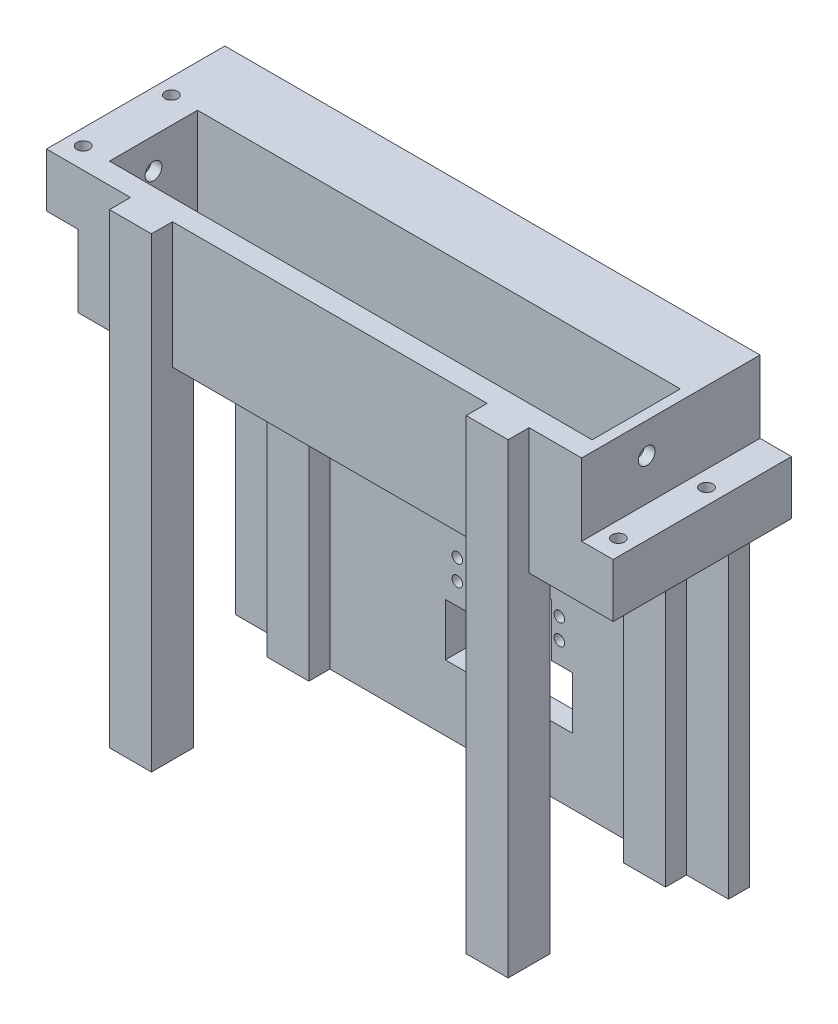
from build123d import *

# Parameters (mm, degrees)
SKETCH2_W            = 230
SKETCH2_H            = 42
BOSS_EXTRUDE1_DEPTH  = 60
BOSS_EXTRUDE2_DEPTH  = 150
SKETCH5_R            = 4
CUT_EXTRUDE1_DEPTH   = 277
SKETCH7_R            = 4
BOSS_EXTRUDE3_DEPTH  = 20
SKETCH7_2_R          = 4
CUT_EXTRUDE2_DEPTH   = 10
SKETCH8_W            = 62
SKETCH8_H            = 24.6
BOSS_EXTRUDE4_DEPTH  = 14
SKETCH9_W            = 62
SKETCH9_H            = 24.6
BOSS_EXTRUDE5_DEPTH  = 14
SKETCH15_W           = 42
SKETCH15_H           = 60
SKETCH15_R           = 4
CUT_EXTRUDE3_DEPTH   = 5
SKETCH17_W           = 42
SKETCH17_H           = 60
SKETCH17_R           = 4
CUT_EXTRUDE4_DEPTH   = 5
SKETCH18_W           = 1
SKETCH18_H           = 62
BOSS_EXTRUDE9_DEPTH  = 24.6
SKETCH18_3_R         = 3
CUT_EXTRUDE5_DEPTH   = 35
SKETCH19_W           = 1
SKETCH19_H           = 62
BOSS_EXTRUDE10_DEPTH = 24.6
SKETCH19_3_R         = 3
CUT_EXTRUDE6_DEPTH   = 27
SKETCH20_W           = 15
SKETCH20_H           = 62
SKETCH20_R           = 3
BOSS_EXTRUDE11_DEPTH = 1
SKETCH21_W           = 15
SKETCH21_H           = 62
SKETCH21_R           = 3
BOSS_EXTRUDE12_DEPTH = 1
SKETCH23_W           = 255
SKETCH23_H           = 10
BOSS_EXTRUDE13_DEPTH = 150
SKETCH25_W           = 251.390716306
SKETCH25_H           = 22.262694164
CUT_EXTRUDE7_DEPTH   = 150
BOSS_EXTRUDE16_DEPTH = 17
CUT_EXTRUDE8_DEPTH   = 150
SKETCH28_W           = 255
SKETCH28_H           = 13
CUT_EXTRUDE9_DEPTH   = 167
BOSS_EXTRUDE18_DEPTH = 6
CUT_EXTRUDE10_DEPTH  = 43
SKETCH32_W           = 10
SKETCH32_H           = 20
BOSS_EXTRUDE19_DEPTH = 7.5
SKETCH33_W           = 10
SKETCH33_H           = 20
BOSS_EXTRUDE20_DEPTH = 8
SKETCH38_R           = 2.5
CUT_EXTRUDE12_DEPTH  = 16
SKETCH40_W           = 20.026518065
SKETCH40_H           = 12.666252083
CUT_EXTRUDE13_DEPTH  = 116
SKETCH41_W           = 84.423481935
SKETCH41_H           = 10
SKETCH41_W_2         = 110.05
BOSS_EXTRUDE21_DEPTH = 61.47
SKETCH42_W           = 10
SKETCH42_H           = 25
CUT_EXTRUDE14_DEPTH  = 10
SKETCH40_3_W         = 20
SKETCH40_3_H         = 10
BOSS_EXTRUDE22_DEPTH = 162.1
SKETCH43_W           = 10
SKETCH43_H           = 31.300449652
BOSS_EXTRUDE23_DEPTH = 40.5
BOSS_EXTRUDE24_START = -60
SKETCH46_W           = 20
SKETCH46_H           = 20
BOSS_EXTRUDE24_DEPTH = 222.1
SKETCH48_R           = 2
CUT_EXTRUDE15_DEPTH  = 30


with BuildPart() as part:
    # Sketch2 → Boss-Extrude1 (new body)
    with BuildSketch(Plane(origin=(0, 0, 0), x_dir=(1, 0, 0), z_dir=(0, 1, 0))):
        Polygon((-125, -31), (125, -31), (125, -21), (125, 0), (125, 21), (125, 31), (-125, 31), (-125, 21), (-125, 0), (-125, -21), align=None)
        Rectangle(SKETCH2_W, SKETCH2_H, mode=Mode.SUBTRACT)
    extrude(amount=BOSS_EXTRUDE1_DEPTH)

    # Sketch4 → Boss-Extrude2 (add)
    with BuildSketch(Plane.XZ):
        Polygon((125, 31), (-125, 31), (-125, 21), (-115, 21), (125, 21), align=None)
    extrude(amount=BOSS_EXTRUDE2_DEPTH)

    # Sketch5 → Cut-Extrude1 (cut)
    with BuildSketch(Plane.ZY.offset(125)):
        with Locations((0, 15.395589143)):
            Circle(SKETCH5_R)
        with Locations((0, 45.395589143)):
            Circle(SKETCH5_R)
    extrude(amount=-CUT_EXTRUDE1_DEPTH, mode=Mode.SUBTRACT)

    # Sketch7 → Boss-Extrude3 (add)
    with BuildSketch(Plane(origin=(125, 0, 0), x_dir=(0, 0, -1), z_dir=(1, 0, 0))):
        Polygon((-21, -150), (-31, -150), (-31, 60), (31, 60), (31, 0), (-21, 0), align=None)
        with Locations((0, 15.395589143)):
            Circle(SKETCH7_R, mode=Mode.SUBTRACT)
        with Locations((0, 45.395589143)):
            Circle(SKETCH7_R, mode=Mode.SUBTRACT)
    extrude(amount=-BOSS_EXTRUDE3_DEPTH)

    # Sketch7_2 → Cut-Extrude2 (cut)
    with BuildSketch(Plane(origin=(125, 0, 0), x_dir=(0, 0, -1), z_dir=(1, 0, 0))):
        Polygon((-21, -150), (-31, -150), (-31, 60), (31, 60), (31, 0), (-21, 0), align=None)
        with Locations((0, 15.395589143)):
            Circle(SKETCH7_2_R, mode=Mode.SUBTRACT)
        with Locations((0, 45.395589143)):
            Circle(SKETCH7_2_R, mode=Mode.SUBTRACT)
    extrude(amount=-CUT_EXTRUDE2_DEPTH, mode=Mode.SUBTRACT)

    # Sketch8 → Boss-Extrude4 (add)
    with BuildSketch(Plane(origin=(115, 0, 0), x_dir=(0, 0, -1), z_dir=(1, 0, 0))):
        with Locations((0, 12.3)):
            Rectangle(SKETCH8_W, SKETCH8_H)
    extrude(amount=BOSS_EXTRUDE4_DEPTH)

    # Sketch9 → Boss-Extrude5 (add)
    with BuildSketch(Plane.ZY.offset(125)):
        with Locations((0, 47.7)):
            Rectangle(SKETCH9_W, SKETCH9_H)
    extrude(amount=BOSS_EXTRUDE5_DEPTH)

    # Sketch15 → Cut-Extrude3 (cut)
    with BuildSketch(Plane.ZY.offset(-105)):
        with Locations((0, 30)):
            Rectangle(SKETCH15_W, SKETCH15_H)
        with Locations((0, 15.395589143)):
            Circle(SKETCH15_R, mode=Mode.SUBTRACT)
        with Locations((0, 45.395589143)):
            Circle(SKETCH15_R, mode=Mode.SUBTRACT)
    extrude(amount=-CUT_EXTRUDE3_DEPTH, mode=Mode.SUBTRACT)

    # Sketch17 → Cut-Extrude4 (cut)
    with BuildSketch(Plane(origin=(-115, 0, 0), x_dir=(0, 0, -1), z_dir=(1, 0, 0))):
        with Locations((0, 30)):
            Rectangle(SKETCH17_W, SKETCH17_H)
        with Locations((0, 45.395589143)):
            Circle(SKETCH17_R, mode=Mode.SUBTRACT)
        with Locations((0, 15.395589143)):
            Circle(SKETCH17_R, mode=Mode.SUBTRACT)
    extrude(amount=-CUT_EXTRUDE4_DEPTH, mode=Mode.SUBTRACT)

    # Sketch18 → Boss-Extrude9 (add)
    with BuildSketch(Plane.XZ.offset(-35.4)):
        with Locations((-139.5, 0)):
            Rectangle(SKETCH18_W, SKETCH18_H)
    extrude(amount=-BOSS_EXTRUDE9_DEPTH)

    # Sketch18_3 → Cut-Extrude5 (cut)
    with BuildSketch(Plane.XZ.offset(-35.4)):
        with Locations((-132.5, 21)):
            Circle(SKETCH18_3_R)
        with Locations((-132.5, -21)):
            Circle(SKETCH18_3_R)
    extrude(amount=-CUT_EXTRUDE5_DEPTH, mode=Mode.SUBTRACT)

    # Sketch19 → Boss-Extrude10 (add)
    with BuildSketch(Plane(origin=(0, 24.6, 0), x_dir=(1, 0, 0), z_dir=(0, 1, 0))):
        with Locations((129.5, 0)):
            Rectangle(SKETCH19_W, SKETCH19_H)
    extrude(amount=-BOSS_EXTRUDE10_DEPTH)

    # Sketch19_3 → Cut-Extrude6 (cut)
    with BuildSketch(Plane(origin=(0, 24.6, 0), x_dir=(1, 0, 0), z_dir=(0, 1, 0))):
        with Locations((122.5, 21)):
            Circle(SKETCH19_3_R)
        with Locations((122.5, -21)):
            Circle(SKETCH19_3_R)
    extrude(amount=-CUT_EXTRUDE6_DEPTH, mode=Mode.SUBTRACT)

    # Sketch20 → Boss-Extrude11 (add)
    with BuildSketch(Plane(origin=(0, 24.6, 0), x_dir=(1, 0, 0), z_dir=(0, 1, 0))):
        with Locations((122.5, 0)):
            Rectangle(SKETCH20_W, SKETCH20_H)
        with Locations((122.5, -21)):
            Circle(SKETCH20_R, mode=Mode.SUBTRACT)
        with Locations((122.5, 21)):
            Circle(SKETCH20_R, mode=Mode.SUBTRACT)
    extrude(amount=BOSS_EXTRUDE11_DEPTH)

    # Sketch21 → Boss-Extrude12 (add)
    with BuildSketch(Plane.XZ.offset(-35.4)):
        with Locations((-132.5, 0)):
            Rectangle(SKETCH21_W, SKETCH21_H)
        with Locations((-132.5, 21)):
            Circle(SKETCH21_R, mode=Mode.SUBTRACT)
        with Locations((-132.5, -21)):
            Circle(SKETCH21_R, mode=Mode.SUBTRACT)
    extrude(amount=BOSS_EXTRUDE12_DEPTH)

    # Sketch23 → Boss-Extrude13 (add)
    with BuildSketch(Plane.XZ):
        with Locations((2.5, -26)):
            Rectangle(SKETCH23_W, SKETCH23_H)
    extrude(amount=BOSS_EXTRUDE13_DEPTH)

    # Sketch25 → Cut-Extrude7 (cut)
    with BuildSketch(Plane.XZ):
        with Locations((-4.583562675, 27.327499947)):
            Rectangle(SKETCH25_W, SKETCH25_H)
    extrude(amount=CUT_EXTRUDE7_DEPTH, mode=Mode.SUBTRACT)

    # Sketch26 → Boss-Extrude16 (add)
    with BuildSketch(Plane(origin=(0, 0, -31), x_dir=(-1, 0, 0), z_dir=(0, 0, -1))):
        Polygon((125, -150), (-130, -150), (-130, 25.6), (-115, 25.6), (-115, 60), (125, 60), (140, 60), (140, 34.4), (125, 34.4), (125, 25.6), align=None)
    extrude(amount=BOSS_EXTRUDE16_DEPTH)

    # Sketch27 → Cut-Extrude8 (cut)
    with BuildSketch(Plane.XZ):
        Polygon((110, -31), (132.347433228, -31), (132.347433228, -21), (110, -21), (-153.412168614, -21), (-153.412168614, -31), align=None)
    extrude(amount=CUT_EXTRUDE8_DEPTH, mode=Mode.SUBTRACT)

    # Sketch28 → Cut-Extrude9 (cut)
    with BuildSketch(Plane.XZ):
        with Locations((2.5, -37.5)):
            Rectangle(SKETCH28_W, SKETCH28_H)
    extrude(amount=CUT_EXTRUDE9_DEPTH, mode=Mode.SUBTRACT)

    # Sketch29 → Boss-Extrude18 (add)
    with BuildSketch(Plane(origin=(0, 0, -48), x_dir=(-1, 0, 0), z_dir=(0, 0, -1))):
        Polygon((125, -150), (-130, -150), (-130, 25.6), (-115, 25.6), (-115, 60), (125, 60), (140, 60), (140, 34.4), (125, 34.4), (125, 25.6), align=None)
    extrude(amount=BOSS_EXTRUDE18_DEPTH)

    # Sketch31 → Cut-Extrude10 (cut)
    with BuildSketch(Plane.XY.offset(-44)):
        Polygon((33.05, -150), (130, -150), (130, -100.63), (33.05, -100.63), (33.05, -80.63), (-22.95, -80.63), (-22.95, -100.63), (-125, -100.63), (-125, -150), align=None)
    extrude(amount=-CUT_EXTRUDE10_DEPTH, mode=Mode.SUBTRACT)

    # Sketch32 → Boss-Extrude19 (add)
    with BuildSketch(Plane.ZY.offset(-33.05)):
        with Locations((-49, -90.63)):
            Rectangle(SKETCH32_W, SKETCH32_H)
    extrude(amount=BOSS_EXTRUDE19_DEPTH)

    # Sketch33 → Boss-Extrude20 (add)
    with BuildSketch(Plane(origin=(-22.95, 0, 0), x_dir=(0, 0, -1), z_dir=(1, 0, 0))):
        with Locations((49, -90.63)):
            Rectangle(SKETCH33_W, SKETCH33_H)
    extrude(amount=BOSS_EXTRUDE20_DEPTH)

    # Sketch38 → Cut-Extrude12 (cut)
    with BuildSketch(Plane.XY.offset(-44)):
        with Locations((29.35, -95.53)):
            Circle(SKETCH38_R)
        with Locations((29.35, -85.73)):
            Circle(SKETCH38_R)
        with Locations((-19.25, -95.53)):
            Circle(SKETCH38_R)
        with Locations((-19.25, -85.73)):
            Circle(SKETCH38_R)
    extrude(amount=-CUT_EXTRUDE12_DEPTH, mode=Mode.SUBTRACT)

    # Sketch40 → Cut-Extrude13 (cut)
    with BuildSketch(Plane.XZ):
        with Locations((119.986740967, -50.333126042)):
            Rectangle(SKETCH40_W, SKETCH40_H)
    extrude(amount=CUT_EXTRUDE13_DEPTH, mode=Mode.SUBTRACT)

    # Sketch41 → Boss-Extrude21 (add)
    with BuildSketch(Plane.XZ.offset(100.63)):
        with Locations((67.761740968, -49)):
            Rectangle(SKETCH41_W, SKETCH41_H)
        with Locations((-69.975, -49)):
            Rectangle(SKETCH41_W_2, SKETCH41_H)
    extrude(amount=BOSS_EXTRUDE21_DEPTH)

    # Sketch42 → Cut-Extrude14 (cut)
    with BuildSketch(Plane.ZY.offset(-25.55)):
        with Locations((-49, -118.299550348)):
            Rectangle(SKETCH42_W, SKETCH42_H)
    cut_extrude14 = extrude(amount=-CUT_EXTRUDE14_DEPTH, mode=Mode.SUBTRACT)

    # Mirror1: Cut-Extrude14 across plane
    add(cut_extrude14.mirror(Plane.ZY.offset(-5.3)), mode=Mode.SUBTRACT)

    # Sketch40_3 → Boss-Extrude22 (add)
    with BuildSketch(Plane.XZ):
        with Locations((79.973481935, -39)):
            Rectangle(SKETCH40_3_W, SKETCH40_3_H)
        with Locations((-89.973481935, -39)):
            Rectangle(SKETCH40_3_W, SKETCH40_3_H)
    extrude(amount=BOSS_EXTRUDE22_DEPTH)

    # Sketch43 → Boss-Extrude23 (add)
    with BuildSketch(Plane.ZY.offset(-25.55)):
        with Locations((-49, -146.449775174)):
            Rectangle(SKETCH43_W, SKETCH43_H)
    extrude(amount=BOSS_EXTRUDE23_DEPTH)

    # Sketch46 → Boss-Extrude24 (add)
    with BuildSketch(Plane.XZ.offset(BOSS_EXTRUDE24_START)):
        with Locations((79.973481935, 31)):
            Rectangle(SKETCH46_W, SKETCH46_H)
        with Locations((-89.973481935, 31)):
            Rectangle(SKETCH46_W, SKETCH46_H)
    extrude(amount=BOSS_EXTRUDE24_DEPTH)

    # Sketch48 → Cut-Extrude15 (cut)
    with BuildSketch(Plane.XZ.offset(162.1)):
        with Locations((79.973481935, 31)):
            Circle(SKETCH48_R)
        with Locations((79.973481935, -44)):
            Circle(SKETCH48_R)
        with Locations((-89.973481935, 31)):
            Circle(SKETCH48_R)
        with Locations((-89.973481935, -44)):
            Circle(SKETCH48_R)
    extrude(amount=-CUT_EXTRUDE15_DEPTH, mode=Mode.SUBTRACT)


solid = part.part
